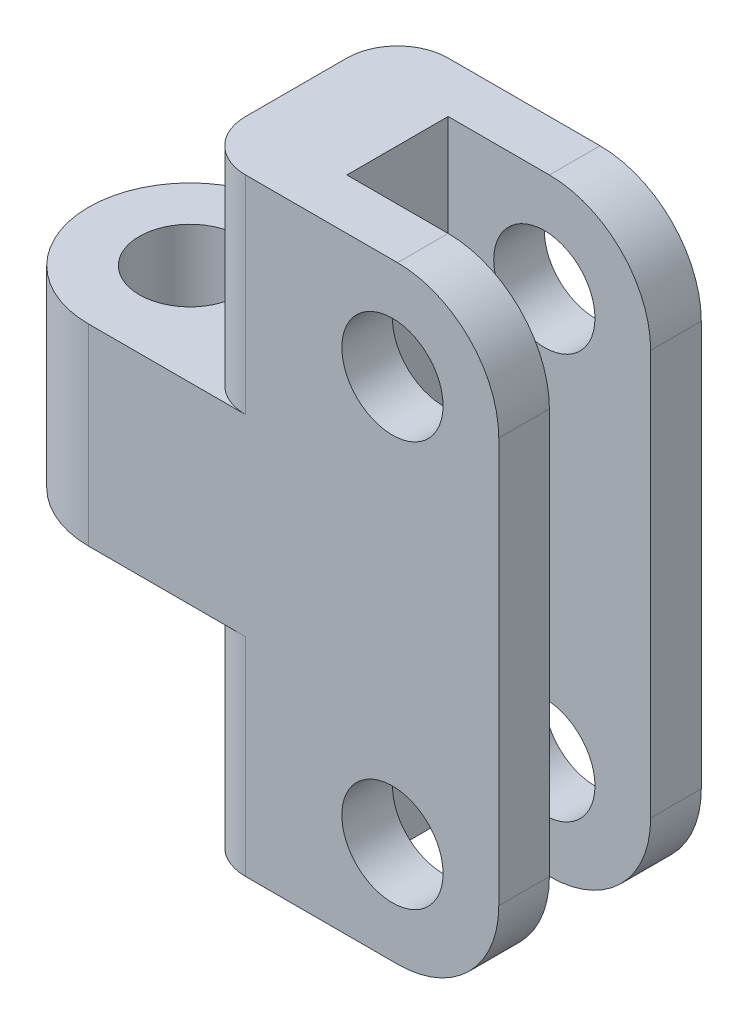
from build123d import *

# Parameters (mm, degrees)
SKETCH1_R           = 5
BOSS_EXTRUDE1_DEPTH = 9.5
BOSS_EXTRUDE2_DEPTH = 30
SKETCH2_R           = 5
CUT_EXTRUDE1_DEPTH  = 21
FILLET1_R           = 10
FILLET2_R           = 5


with BuildPart() as part:
    # Sketch1 → Boss-Extrude1 (new body, symmetric)
    with BuildSketch(Plane(origin=(0, 0, 0), x_dir=(1, 0, 0), z_dir=(0, 1, 0))):
        with BuildLine():
            Line((10.5, 10), (0, 10))
            ThreePointArc((0, 10), (-10, 0), (0, -10))
            Line((0, -10), (10.5, -10))
            Line((10.5, -10), (10.5, 10))
        make_face()
        Circle(SKETCH1_R, mode=Mode.SUBTRACT)
    extrude(amount=BOSS_EXTRUDE1_DEPTH, both=True)

    # Sketch1_3 → Boss-Extrude2 (add, symmetric)
    with BuildSketch(Plane(origin=(0, 0, 0), x_dir=(1, 0, 0), z_dir=(0, 1, 0))):
        Polygon((40.5, 10), (10.5, 10), (10.5, -10), (40.5, -10), (40.5, -5), (20.5, -5), (20.5, 5), (40.5, 5), align=None)
    extrude(amount=BOSS_EXTRUDE2_DEPTH, both=True)

    # Sketch2 → Cut-Extrude1 (cut, through all)
    with BuildSketch(Plane.XY.offset(10)):
        with Locations((30, 20)):
            Circle(SKETCH2_R)
        with Locations((30, -20)):
            Circle(SKETCH2_R)
    extrude(amount=-CUT_EXTRUDE1_DEPTH, mode=Mode.SUBTRACT)

    # Fillet1
    fillet1_edges = [part.edges().sort_by_distance(p)[0] for p in [
        (40.5, -30, -7.5),
        (40.5, -30, 7.5),
        (40.5, 30, -7.5),
        (40.5, 30, 7.5),
    ]]
    fillet(fillet1_edges, radius=FILLET1_R)

    # Fillet2
    fillet2_edges = [part.edges().sort_by_distance(p)[0] for p in [
        (10.5, 19.75, -10),
        (10.5, -19.75, -10),
        (10.5, 19.75, 10),
        (10.5, -19.75, 10),
    ]]
    fillet(fillet2_edges, radius=FILLET2_R)


solid = part.part
